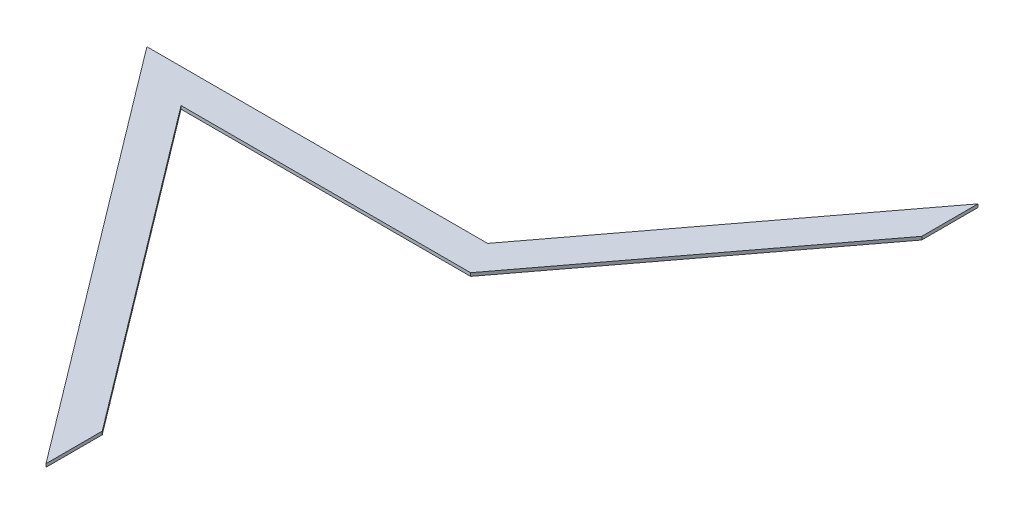
from build123d import *

# Parameters (mm, degrees)
BOSS_EXTRUDE1_DEPTH = 1


with BuildPart() as part:
    # Sketch1 → Boss-Extrude1 (new body)
    with BuildSketch(Plane(origin=(0, 0, 0), x_dir=(1, 0, 0), z_dir=(0, 1, 0))):
        Polygon((74.999436695, 214.999999991), (75, 197.5), (14.618264331, 117.5), (-75.48222233, 117.5), (0, 17.5), (0, 0), (-96.647437471, 128.04), (9.36449003, 128.04), align=None)
    extrude(amount=BOSS_EXTRUDE1_DEPTH)


solid = part.part
